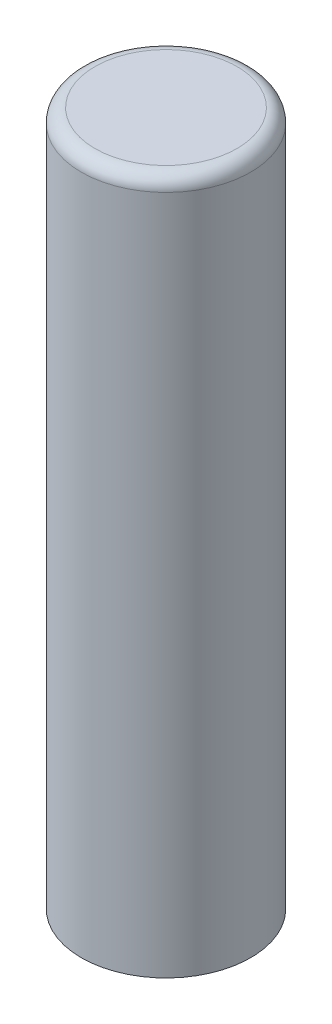
from build123d import *

# Parameters (mm, degrees)
SKETCH1_R           = 1.55
BOSS_EXTRUDE1_DEPTH = 12.7
FILLET1_R           = 0.25


with BuildPart() as part:
    # Sketch1 → Boss-Extrude1 (new body)
    with BuildSketch(Plane(origin=(0, 0, 0), x_dir=(1, 0, 0), z_dir=(0, 1, 0))):
        Circle(SKETCH1_R)
    extrude(amount=BOSS_EXTRUDE1_DEPTH)

    # Fillet1
    fillet1_edges = [part.edges().sort_by_distance(p)[0] for p in [
        (-1.55, 12.7, 0),
    ]]
    fillet(fillet1_edges, radius=FILLET1_R)


solid = part.part
